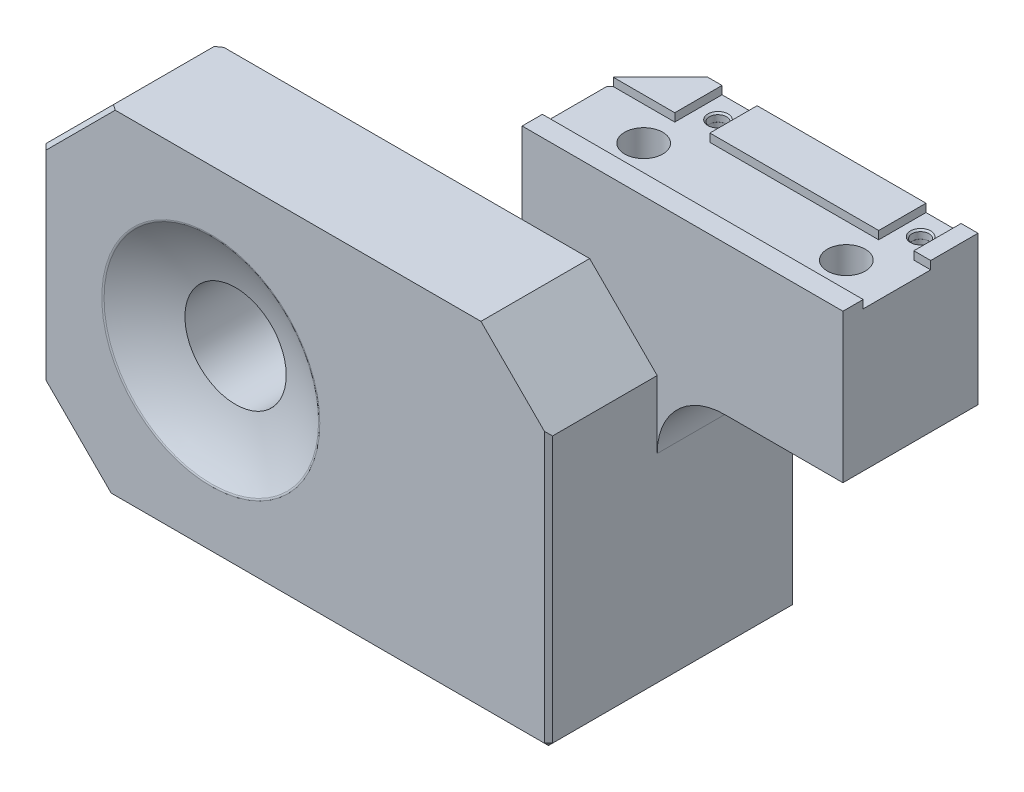
from build123d import *

# Parameters (mm, degrees)
SKETCH1_W                          = 25.4
SKETCH1_H                          = 76.2
EXTRUDE1_DEPTH                     = 20.447
SKETCH60_W                         = 25.4
SKETCH60_H                         = 63.5
EXTRUDE6_DEPTH                     = 63.5
SKETCH69_W                         = 63.5
SKETCH69_H                         = 63.5
SKETCH69_R                         = 22.225
CUT_EXTRUDE23_DEPTH                = 4.953
SKETCH71_R                         = 9.525
CUT_EXTRUDE24_DEPTH                = 24.778013047
SKETCH80_W                         = 20.447
SKETCH80_H                         = 76.2
EXTRUDE11_DEPTH                    = 6.35
SKETCH76_W                         = 25.4
SKETCH76_H                         = 76.2
EXTRUDE9_DEPTH                     = 25.4
SKETCH79_W                         = 50.8
SKETCH79_H                         = 6.35
EXTRUDE10_DEPTH                    = 46.847
SKETCH84_W                         = 60.325
SKETCH84_H                         = 25.4
EXTRUDE14_DEPTH                    = 15.24
EXTRUDE14_DEPTH_BACK               = 12.7
EXTRUDE15_DEPTH                    = 1.524
CBORE_FOR_1_8_PRESS_PIN_AT_2_COUNT = 2
CBORE_FOR_1_8_PRESS_PIN_AT_2_PITCH = 38.1
CHAMFER5_SIZE                      = 9.525
FILLET6_R                          = 12.7
CHAMFER3_SIZE                      = 12.7
FILLET7_R                          = 0.254
CHAMFER4_SIZE                      = 0.762
FILLET4_R                          = 2.54
FILLET5_R                          = 0.635


with BuildPart() as part:
    # Sketch1 → Extrude1 (new body)
    with BuildSketch(Plane.XY):
        with Locations((12.7, 0)):
            Rectangle(SKETCH1_W, SKETCH1_H)
    extrude(amount=EXTRUDE1_DEPTH)

    # Sketch60 → Extrude6 (add)
    with BuildSketch(Plane.ZY):
        with Locations((7.747, 0)):
            Rectangle(SKETCH60_W, SKETCH60_H)
    extrude(amount=EXTRUDE6_DEPTH)

    # Sketch64 → Cut-Revolve1 (revolve, cut)
    with BuildSketch(Plane(origin=(0, 0, 0), x_dir=(-1, 0, 0), z_dir=(0, 1, 0)), mode=Mode.PRIVATE) as cut_revolve1_sk:
        with BuildLine():
            Line((9.525, -4.953), (9.525, 0.012163278))
            ThreePointArc((9.525, 0.012163278), (14.839678796, -1.926851671), (20.32, -3.331013047))
            Line((20.32, -3.331013047), (31.75, -3.331013047))
            Line((31.75, -3.331013047), (31.75, -4.953))
            Line((31.75, -4.953), (9.525, -4.953))
        make_face()
        with BuildLine():
            Line((31.75, 20.447), (11.43, 20.447))
            ThreePointArc((11.43, 20.447), (21.174424434, 16.073156441), (31.75, 14.575986953))
            Line((31.75, 14.575986953), (31.75, 20.447))
        make_face()
    revolve(cut_revolve1_sk.sketch.rotate(Axis((-31.75, 0, 14.575986953), (0, 0, 1)), 180), axis=Axis((-31.75, 0, 14.575986953), (0, 0, 1)), mode=Mode.SUBTRACT)  # turned: the seam where the file's is

    # Sketch69 → Cut-Extrude23 (cut)
    with BuildSketch(Plane(origin=(0, 0, -4.953), x_dir=(-1, 0, 0), z_dir=(0, 0, -1))):
        with Locations((31.75, 0)):
            Rectangle(SKETCH69_W, SKETCH69_H)
        with Locations((31.75, 0)):
            Circle(SKETCH69_R, mode=Mode.SUBTRACT)
    extrude(amount=-CUT_EXTRUDE23_DEPTH, mode=Mode.SUBTRACT)

    # Sketch71 → Cut-Extrude24 (cut, through all)
    with BuildSketch(Plane.XY.offset(20.447)):
        with Locations((-31.75, 0)):
            Circle(SKETCH71_R)
    extrude(amount=-CUT_EXTRUDE24_DEPTH, mode=Mode.SUBTRACT)

    # Sketch80 → Extrude11 (add)
    with BuildSketch(Plane(origin=(25.4, 0, 0), x_dir=(0, 0, -1), z_dir=(1, 0, 0))):
        with Locations((-10.2235, 0)):
            Rectangle(SKETCH80_W, SKETCH80_H)
    extrude(amount=EXTRUDE11_DEPTH)

    # Sketch76 → Extrude9 (add)
    with BuildSketch(Plane(origin=(0, 0, 0), x_dir=(-1, 0, 0), z_dir=(0, 0, -1))):
        with Locations((-19.05, 0)):
            Rectangle(SKETCH76_W, SKETCH76_H)
    extrude(amount=EXTRUDE9_DEPTH)

    # Sketch79 → Extrude10 (cut, through all)
    with BuildSketch(Plane.XY.offset(20.447)):
        with Locations((6.35, -34.925)):
            Rectangle(SKETCH79_W, SKETCH79_H)
        with Locations((6.35, 34.925)):
            Rectangle(SKETCH79_W, SKETCH79_H)
    extrude(amount=-EXTRUDE10_DEPTH, mode=Mode.SUBTRACT)

    # Sketch84 → Extrude14 (add, two sides)
    with BuildSketch(Plane(origin=(0, 31.75, 0), x_dir=(1, 0, 0), z_dir=(0, 1, 0))) as extrude14_sk:
        with Locations((36.5125, 12.7)):
            Rectangle(SKETCH84_W, SKETCH84_H)
    extrude(amount=EXTRUDE14_DEPTH)
    extrude(extrude14_sk.sketch, amount=-EXTRUDE14_DEPTH_BACK)

    # Sketch85 → CBORE for 1_4 Socket Head Cap Screw1 (revolve, cut)
    with BuildSketch(Plane(origin=(19.05, -31.75, -10.16), x_dir=(0, 0, -1), z_dir=(1, 0, 0))):
        Polygon((0, 0), (0, 78.74), (4.20624, 78.74), (3.57124, 78.105), (3.57124, 50.8), (6.35, 50.8), (6.35, 0.762), (7.112, 0), align=None)
    revolve(axis=Axis((19.05, -38.1, -10.16), (0, 1, 0)), mode=Mode.SUBTRACT)

    # Sketch87 → 1_4 Clearance Hole2 (revolve, cut)
    with BuildSketch(Plane(origin=(57.15, 19.05, -10.16), x_dir=(0, 0, -1), z_dir=(1, 0, 0))):
        Polygon((0, 0), (0, 27.94), (4.20624, 27.94), (3.57124, 27.305), (3.57124, 0), align=None)
    revolve(axis=Axis((57.15, 12.7, -10.16), (0, 1, 0)), mode=Mode.SUBTRACT)

    # Sketch89 → Extrude15 (cut)
    with BuildSketch(Plane(origin=(0, 46.99, 0), x_dir=(1, 0, 0), z_dir=(0, 1, 0))):
        Polygon((6.35, 3.81), (66.675, 3.81), (66.675, 16.51), (63.5, 16.51), (63.5, 25.4), (56.896, 25.4), (56.896, 16.51), (25.146, 16.51), (25.146, 25.4), (18.542, 25.4), (18.542, 16.51), (6.35, 16.51), align=None)
    extrude(amount=-EXTRUDE15_DEPTH, mode=Mode.SUBTRACT)

    # Sketch90 → CBORE for 1_8_ Press Pin (revolve, cut)
    with BuildSketch(Plane(origin=(22.225, 45.466, -20.955), x_dir=(0, 0, 1), z_dir=(1, 0, 0))):
        Polygon((0, 0), (0, 7.303866233), (1.5875, 6.35), (1.5875, 1.524), (1.6002, 1.524), (1.6002, 0.3048), (1.905, 0), align=None)
    cbore_for_1_8_press_pin = revolve(axis=Axis((22.225, 51.816, -20.955), (0, -1, 0)), mode=Mode.SUBTRACT)

    # CBORE for 1_8_ Press Pin at 2: CBORE for 1_8_ Press Pin ×2
    with Locations(*[(i * CBORE_FOR_1_8_PRESS_PIN_AT_2_PITCH, 0, 0) for i in range(1, CBORE_FOR_1_8_PRESS_PIN_AT_2_COUNT)]):
        add(cbore_for_1_8_press_pin, mode=Mode.SUBTRACT)

    # Chamfer5
    chamfer5_edges = [part.edges().sort_by_distance(p)[0] for p in [
        (6.35, 7.62, -25.4),
    ]]
    chamfer(chamfer5_edges, length=CHAMFER5_SIZE)

    # Fillet6
    fillet6_edges = [part.edges().sort_by_distance(p)[0] for p in [
        (31.75, 19.05, -12.7),
    ]]
    fillet(fillet6_edges, radius=FILLET6_R)

    # Chamfer3
    chamfer3_edges = [part.edges().sort_by_distance(p)[0] for p in [
        (-63.5, 31.75, 10.2235),
        (-63.5, -31.75, 10.2235),
        (31.75, 31.75, 10.2235),
    ]]
    chamfer(chamfer3_edges, length=CHAMFER3_SIZE)

    # Fillet7
    fillet7_edges = [part.edges().sort_by_distance(p)[0] for p in [
        (6.35, 0, 0),
    ]]
    fillet(fillet7_edges, radius=FILLET7_R)

    # Chamfer4
    chamfer4_edges = [part.edges().sort_by_distance(p)[0] for p in [
        (23.8125, -31.75, -25.4),
        (-9.525, -31.75, 20.447),
        (31.75, -6.35, 20.447),
        (31.75, -31.75, -2.4765),
        (-22.352, -31.75, 0),
        (6.275605122, -31.75, -0.074394878),
        (6.35, -31.75, -8.0645),
        (-57.15, 25.4, 20.447),
        (-57.15, 25.4, 0),
        (-57.15, -25.4, 0),
        (-57.15, -25.4, 20.447),
        (-63.5, 0, 20.447),
        (-63.5, 0, 0),
        (11.1125, -31.75, -20.6375),
    ]]
    chamfer(chamfer4_edges, length=CHAMFER4_SIZE)

    # Fillet4
    fillet4_edges = [part.edges().sort_by_distance(p)[0] for p in [
        (-20.32, 0, -3.331013047),
    ]]
    fillet(fillet4_edges, radius=FILLET4_R)

    # Fillet5
    fillet5_edges = [part.edges().sort_by_distance(p)[0] for p in [
        (-11.43, 0, 20.447),
    ]]
    fillet(fillet5_edges, radius=FILLET5_R)


solid = part.part
